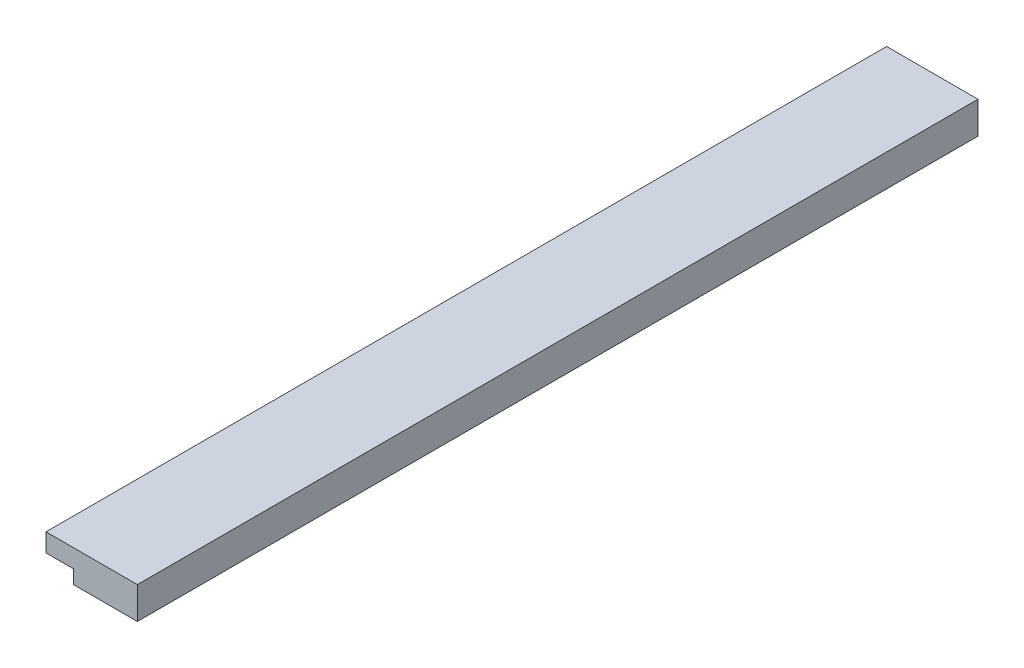
from build123d import *

# Parameters (mm, degrees)
SKETCH_1_W          = 10
SKETCH_1_H          = 92
EXTRUDE_1_DEPTH     = 3.5
SKETCH_2_W          = 7
SKETCH_2_H          = 7
EXTRUDE_2_DEPTH     = 7
SKETCH_3_R          = 1.5
CUT_EXTRUDE_1_DEPTH = 7
SKETCH_4_R          = 2.15
CUT_EXTRUDE_2_DEPTH = 1
SKETCH_5_W          = 3
SKETCH_5_H          = 1.5
CUT_EXTRUDE_3_DEPTH = 92
SKETCH_6_W          = 30.020813891
SKETCH_6_H          = 96.833093315
CUT_EXTRUDE_4_DEPTH = 10


with BuildPart() as part:
    # 스케치1 → 보스-돌출1 (new body)
    with BuildSketch(Plane(origin=(0, 0, 0), x_dir=(1, 0, 0), z_dir=(0, 1, 0))):
        Rectangle(SKETCH_1_W, SKETCH_1_H)
    extrude(amount=EXTRUDE_1_DEPTH)

    # 스케치2 → 보스-돌출2 (add)
    with BuildSketch(Plane.XZ):
        with Locations((1.5, 40)):
            Rectangle(SKETCH_2_W, SKETCH_2_H)
        with Locations((1.5, 0)):
            Rectangle(SKETCH_2_W, SKETCH_2_H)
        with Locations((1.5, -40)):
            Rectangle(SKETCH_2_W, SKETCH_2_H)
    extrude(amount=EXTRUDE_2_DEPTH)

    # 스케치3 → 컷-돌출1 (cut)
    with BuildSketch(Plane(origin=(5, 0, 0), x_dir=(0, 0, -1), z_dir=(1, 0, 0))):
        with Locations((-40, -3.5)):
            Circle(SKETCH_3_R)
        with Locations((0, -3.5)):
            Circle(SKETCH_3_R)
        with Locations((40, -3.5)):
            Circle(SKETCH_3_R)
    extrude(amount=-CUT_EXTRUDE_1_DEPTH, mode=Mode.SUBTRACT)

    # 스케치4 → 컷-돌출2 (cut)
    with BuildSketch(Plane.ZY.offset(2)):
        with Locations((-40, -3.5)):
            Circle(SKETCH_4_R)
        with Locations((0, -3.5)):
            Circle(SKETCH_4_R)
        with Locations((40, -3.5)):
            Circle(SKETCH_4_R)
    extrude(amount=-CUT_EXTRUDE_2_DEPTH, mode=Mode.SUBTRACT)

    # 스케치5 → 컷-돌출3 (cut)
    with BuildSketch(Plane(origin=(0, 0, -46), x_dir=(-1, 0, 0), z_dir=(0, 0, -1))):
        with Locations((3.5, 0.75)):
            Rectangle(SKETCH_5_W, SKETCH_5_H)
    extrude(amount=-CUT_EXTRUDE_3_DEPTH, mode=Mode.SUBTRACT)

    # 스케치6 → 컷-돌출4 (cut)
    with BuildSketch(Plane.XZ):
        with Locations((-3.768545255, 0.383256933)):
            Rectangle(SKETCH_6_W, SKETCH_6_H)
    extrude(amount=CUT_EXTRUDE_4_DEPTH, mode=Mode.SUBTRACT)


solid = part.part
